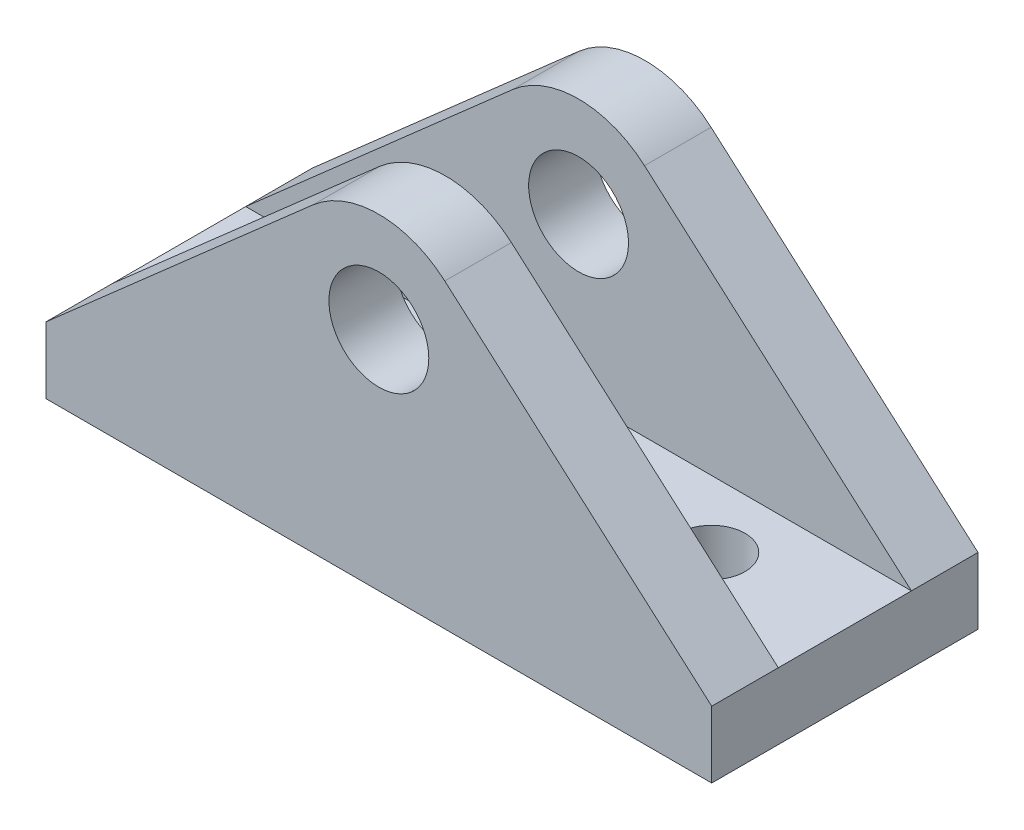
from build123d import *

# Parameters (mm, degrees)
SKETCH1_R           = 4.7625
BOSS_EXTRUDE1_DEPTH = 25.4
SKETCH2_W           = 12.7
SKETCH2_H           = 8.89
SKETCH2_H_2         = 18.382780547
CUT_EXTRUDE1_DEPTH  = 64.5
SKETCH3_R           = 3.175
CUT_EXTRUDE2_DEPTH  = 7.35


with BuildPart() as part:
    # Sketch1 → Boss-Extrude1 (new body)
    with BuildSketch(Plane.XY):
        with BuildLine():
            Line((31.75, -8.89), (6.29056934, 13.502227791))
            ThreePointArc((6.29056934, 13.502227791), (0, 15.875), (-6.29056934, 13.502227791))
            Line((-6.29056934, 13.502227791), (-31.75, -8.89))
            Line((-31.75, -8.89), (-31.75, -15.24))
            Line((-31.75, -15.24), (31.75, -15.24))
            Line((31.75, -15.24), (31.75, -8.89))
        make_face()
        with Locations((0, 6.35)):
            Circle(SKETCH1_R, mode=Mode.SUBTRACT)
    extrude(amount=BOSS_EXTRUDE1_DEPTH)

    # Sketch2 → Cut-Extrude1 (cut, through all)
    with BuildSketch(Plane(origin=(31.75, 0, 0), x_dir=(0, 0, -1), z_dir=(1, 0, 0))):
        with Locations((-12.7, -4.445)):
            Rectangle(SKETCH2_W, SKETCH2_H)
        with Locations((-12.7, 9.191390273)):
            Rectangle(SKETCH2_W, SKETCH2_H_2)
    extrude(amount=-CUT_EXTRUDE1_DEPTH, mode=Mode.SUBTRACT)

    # Sketch3 → Cut-Extrude2 (cut, through all)
    with BuildSketch(Plane(origin=(0, -8.89, 0), x_dir=(1, 0, 0), z_dir=(0, 1, 0))):
        with Locations((-19.05, -12.7)):
            Circle(SKETCH3_R)
        with Locations((19.05, -12.7)):
            Circle(SKETCH3_R)
    extrude(amount=-CUT_EXTRUDE2_DEPTH, mode=Mode.SUBTRACT)


solid = part.part
